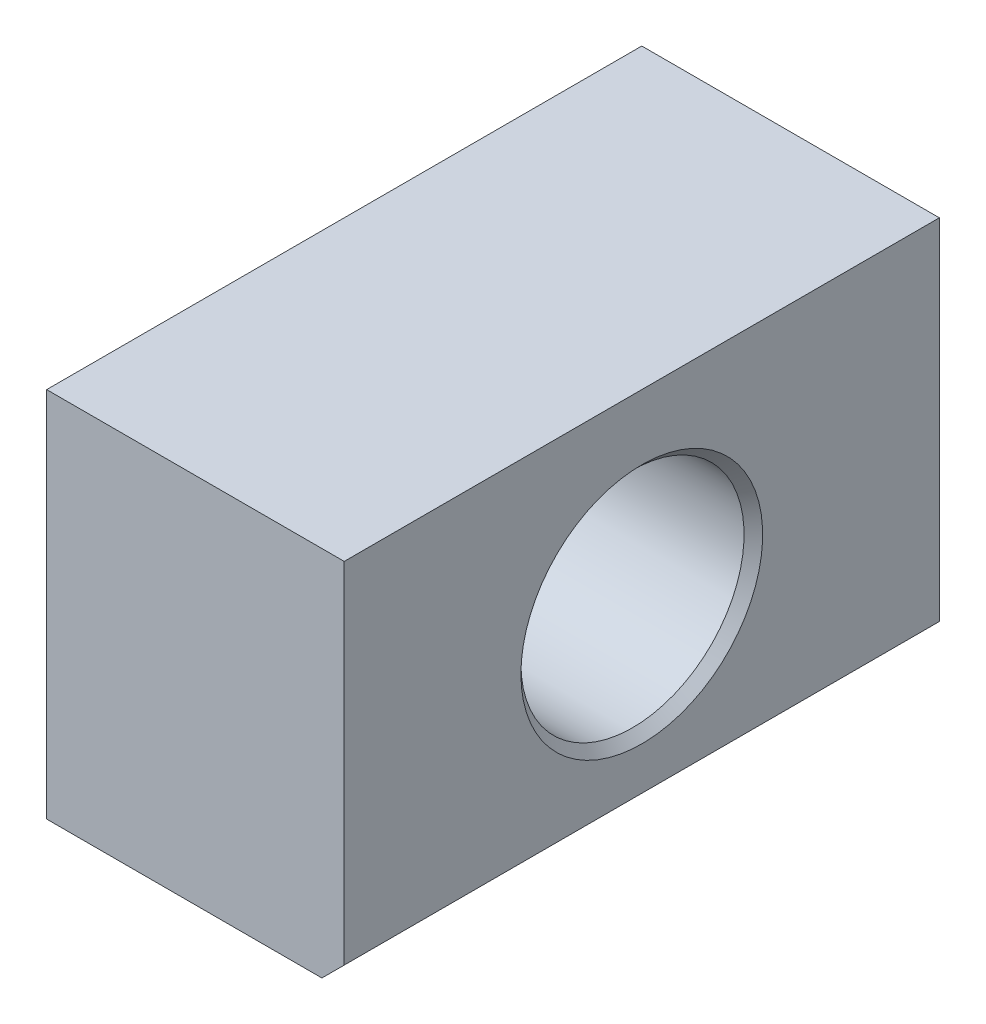
from build123d import *

# Parameters (mm, degrees)
SKETCH_1_W      = 4
SKETCH_1_H      = 5
EXTRUDE_1_DEPTH = 8
CHAMFER_1_SIZE  = 0.3


with BuildPart() as part:
    # Эскиз1 → Бобышка-Вытянуть1 (new body)
    with BuildSketch(Plane.XY):
        Rectangle(SKETCH_1_W, SKETCH_1_H)
    extrude(amount=EXTRUDE_1_DEPTH)

    # Эскиз2 → Отверстие обработанное метчиком M31 (revolve, cut)
    with BuildSketch(Plane(origin=(-2, 0, 4), x_dir=(0, 0, 1), z_dir=(0, 1, 0))):
        Polygon((0, 0), (0, 4), (1.625, 4), (1.5, 3.875), (1.5, 0.125), (1.625, 0), align=None)
    revolve(axis=Axis((-8.35, 0, 4), (1, 0, 0)), mode=Mode.SUBTRACT)

    # Фаска1
    chamfer_1_edges = [part.edges().sort_by_distance(p)[0] for p in [
        (2, -2.5, 4),
    ]]
    chamfer(chamfer_1_edges, length=CHAMFER_1_SIZE)


solid = part.part
